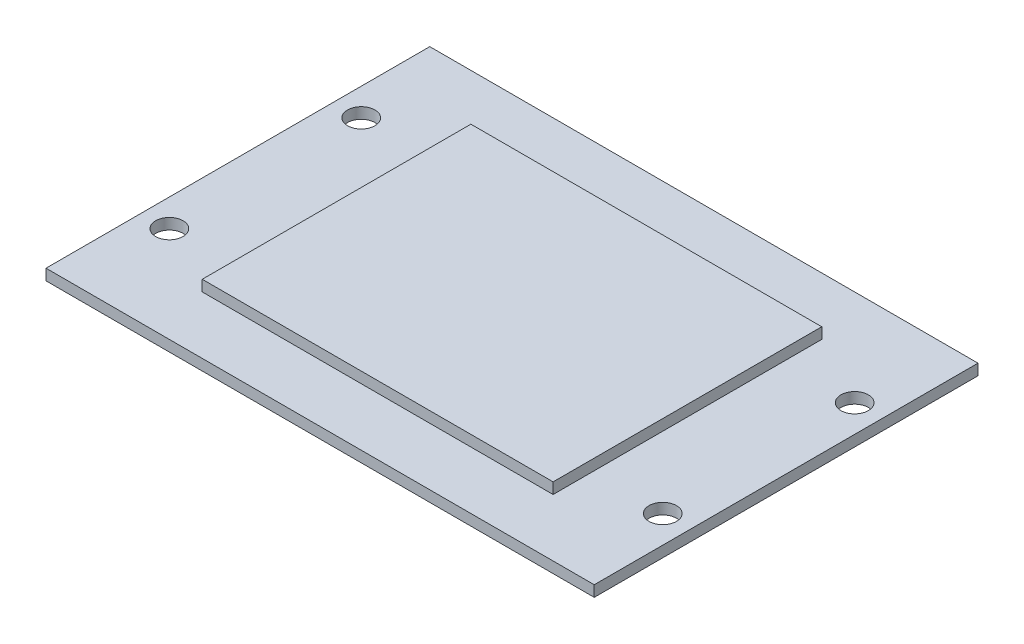
from build123d import *

# Parameters (mm, degrees)
SKETCH1_W           = 100
SKETCH1_H           = 70
BOSS_EXTRUDE1_DEPTH = 2
SKETCH2_W           = 64
SKETCH2_H           = 49
BOSS_EXTRUDE2_DEPTH = 2
SKETCH3_R           = 2.5
CUT_EXTRUDE1_DEPTH  = 2


with BuildPart() as part:
    # Sketch1 → Boss-Extrude1 (new body)
    with BuildSketch(Plane(origin=(0, 0, 0), x_dir=(1, 0, 0), z_dir=(0, 1, 0))):
        with Locations((2.867538216, -9.96520279)):
            Rectangle(SKETCH1_W, SKETCH1_H)
    extrude(amount=BOSS_EXTRUDE1_DEPTH)

    # Sketch2 → Boss-Extrude2 (add)
    with BuildSketch(Plane(origin=(0, 2, 0), x_dir=(1, 0, 0), z_dir=(0, 1, 0))):
        with Locations((2.867538216, -9.96520279)):
            Rectangle(SKETCH2_W, SKETCH2_H)
    extrude(amount=BOSS_EXTRUDE2_DEPTH)

    # Sketch3 → Cut-Extrude1 (cut)
    with BuildSketch(Plane(origin=(0, 2, 0), x_dir=(1, 0, 0), z_dir=(0, 1, 0))):
        with Locations((-42.132461784, 7.53479721)):
            Circle(SKETCH3_R)
        with Locations((47.867538216, 7.53479721)):
            Circle(SKETCH3_R)
        with Locations((47.867538216, -27.46520279)):
            Circle(SKETCH3_R)
        with Locations((-42.132461784, -27.46520279)):
            Circle(SKETCH3_R)
    extrude(amount=-CUT_EXTRUDE1_DEPTH, mode=Mode.SUBTRACT)


solid = part.part
